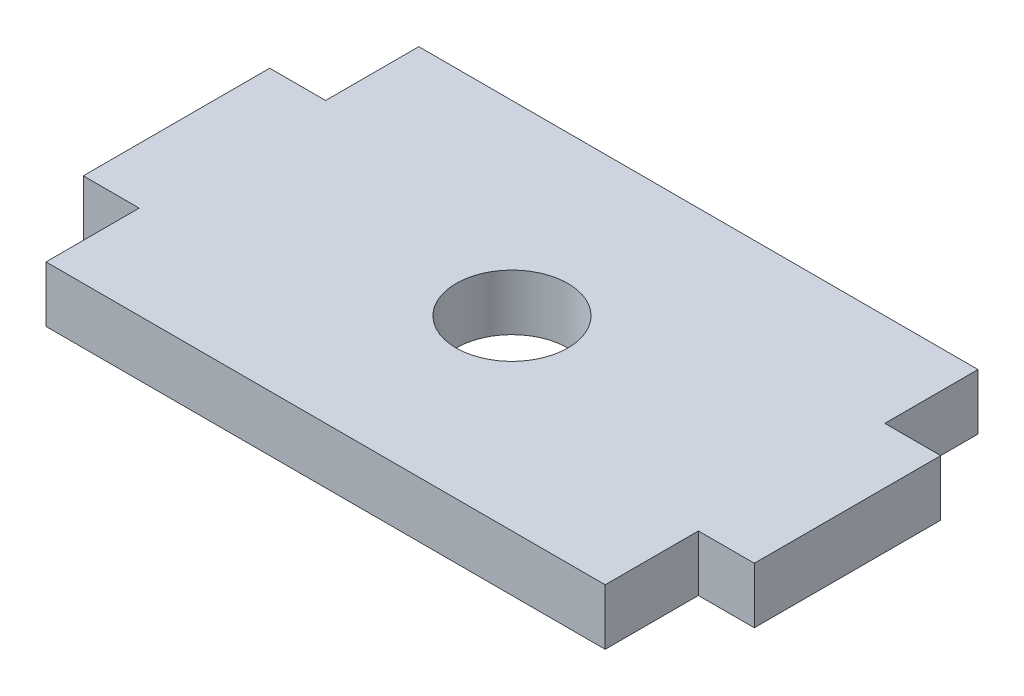
from build123d import *

# Parameters (mm, degrees)
SKETCH1_R           = 3
BOSS_EXTRUDE1_DEPTH = 3


with BuildPart() as part:
    # Sketch1 → Boss-Extrude1 (new body)
    with BuildSketch(Plane(origin=(0, 0, 0), x_dir=(1, 0, 0), z_dir=(0, 1, 0))):
        Polygon((-15, 10), (-15, 5), (-18, 5), (-18, -5), (-15, -5), (-15, -10), (15, -10), (15, -5), (18, -5), (18, 5), (15, 5), (15, 10), align=None)
        Circle(SKETCH1_R, mode=Mode.SUBTRACT)
    extrude(amount=BOSS_EXTRUDE1_DEPTH)


solid = part.part
